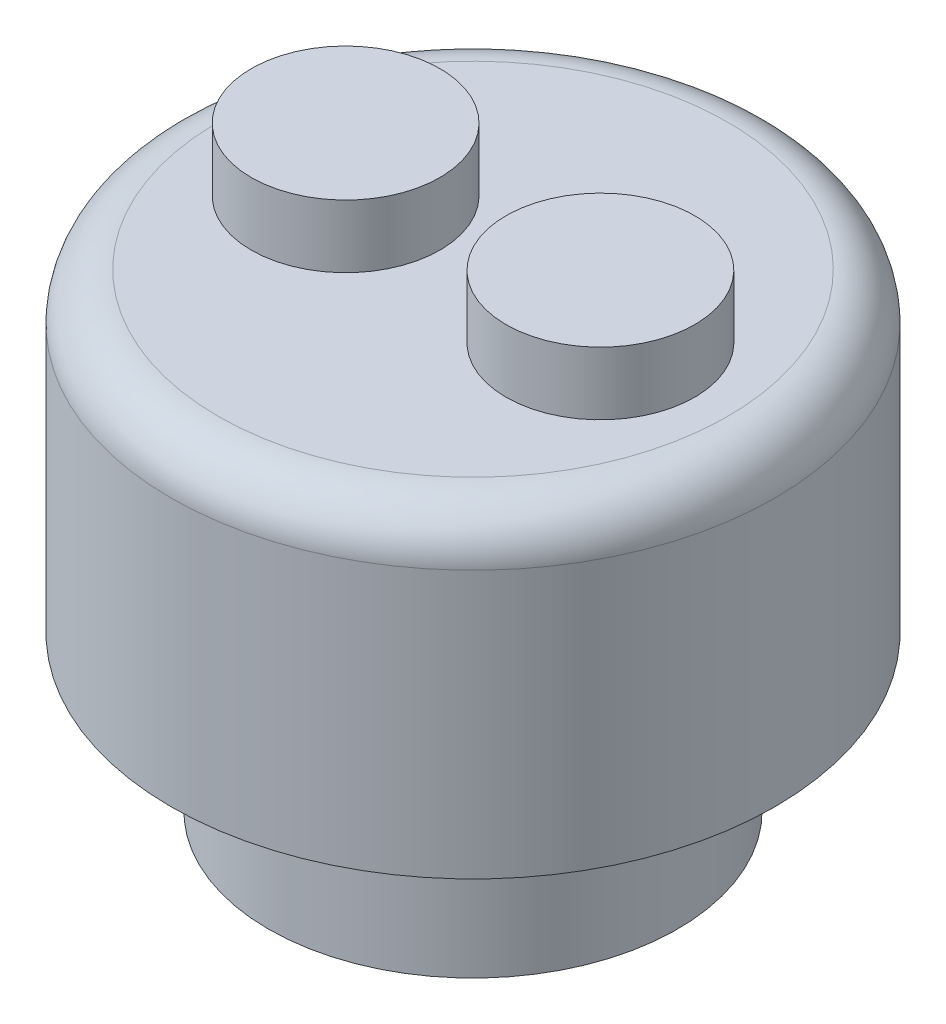
from build123d import *

# Parameters (mm, degrees)
SKETCH1_R           = 3.25
BOSS_EXTRUDE1_DEPTH = 2.46
SKETCH2_R           = 1.75
CUT_EXTRUDE1_DEPTH  = 2.5
SKETCH6_R           = 4.8
BOSS_EXTRUDE2_DEPTH = 5
FILLET2_R           = 0.75
SKETCH7_R           = 1.5
BOSS_EXTRUDE3_DEPTH = 1


with BuildPart() as part:
    # Sketch1 → Boss-Extrude1 (new body)
    with BuildSketch(Plane(origin=(0, 0, 0), x_dir=(1, 0, 0), z_dir=(0, 1, 0))):
        Circle(SKETCH1_R)
    extrude(amount=BOSS_EXTRUDE1_DEPTH)

    # Sketch2 → Cut-Extrude1 (cut)
    with BuildSketch(Plane.XZ):
        Circle(SKETCH2_R)
    extrude(amount=-CUT_EXTRUDE1_DEPTH, mode=Mode.SUBTRACT)

    # Sketch6 → Boss-Extrude2 (add)
    with BuildSketch(Plane(origin=(0, 2.46, 0), x_dir=(1, 0, 0), z_dir=(0, 1, 0))):
        Circle(SKETCH6_R)
    extrude(amount=BOSS_EXTRUDE2_DEPTH)

    # Fillet2
    fillet2_edges = [part.edges().sort_by_distance(p)[0] for p in [
        (-4.8, 7.46, 0),
    ]]
    fillet(fillet2_edges, radius=FILLET2_R)

    # Sketch7 → Boss-Extrude3 (add)
    with BuildSketch(Plane(origin=(0, 7.46, 0), x_dir=(1, 0, 0), z_dir=(0, 1, 0))):
        with Locations((-2.025, 0)):
            Circle(SKETCH7_R)
        with Locations((2.025, 0)):
            Circle(SKETCH7_R)
    extrude(amount=BOSS_EXTRUDE3_DEPTH)


solid = part.part
